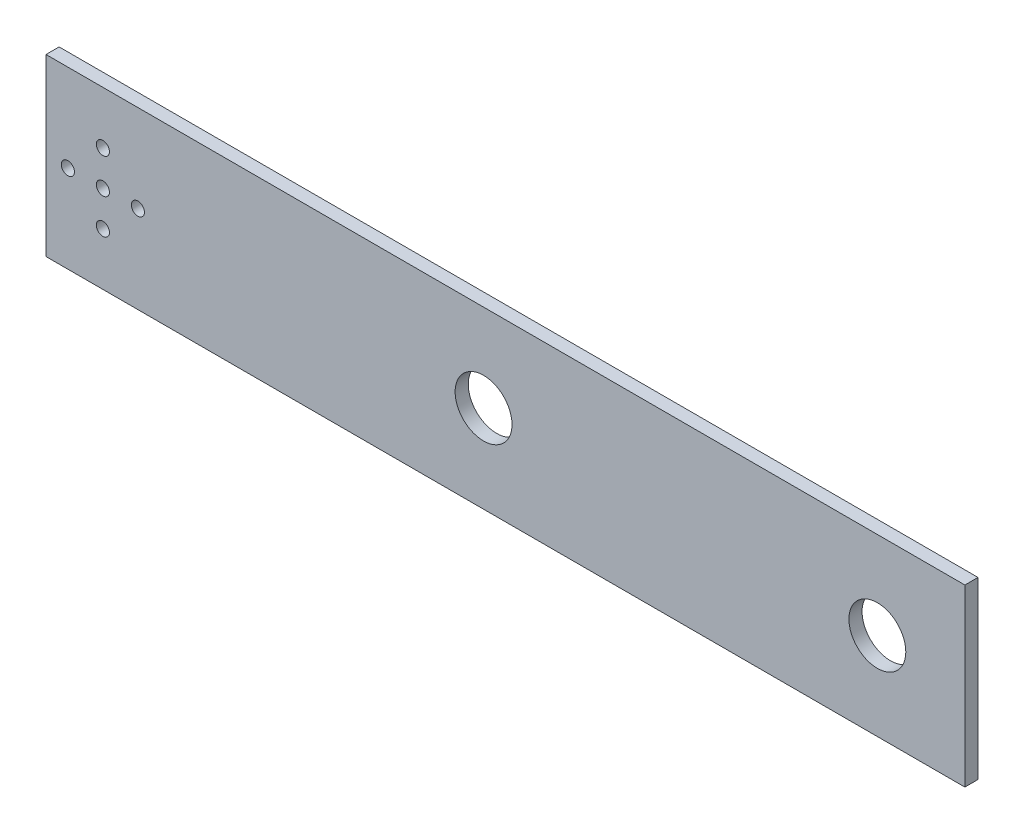
from build123d import *

# Parameters (mm, degrees)
SKETCH1_W                  = 210
SKETCH1_H                  = 40
BOSS_EXTRUDE1_DEPTH        = 3
F_3_0_3_DIAMETER_HOLE2_D   = 3
F_13_0_13_DIAMETER_HOLE1_D = 13


with BuildPart() as part:
    # Sketch1 → Boss-Extrude1 (new body)
    with BuildSketch(Plane.XY):
        with Locations((95, 0)):
            Rectangle(SKETCH1_W, SKETCH1_H)
    extrude(amount=BOSS_EXTRUDE1_DEPTH)

    # Ø3.0 (3) Diameter Hole2 (through all)
    with Locations(Plane(origin=(0, 0, 0), x_dir=(-1, 0, 0), z_dir=(0, 0, -1))):
        with Locations((-3, 8), (-11, 0), (5, 0), (-3, -8), (-3, 0)):
            Hole(F_3_0_3_DIAMETER_HOLE2_D / 2)

    # Ø13.0 (13) Diameter Hole1 (through all)
    with Locations(Plane.XY.offset(3)):
        with Locations((90, 0), (180, 0)):
            Hole(F_13_0_13_DIAMETER_HOLE1_D / 2)


solid = part.part
